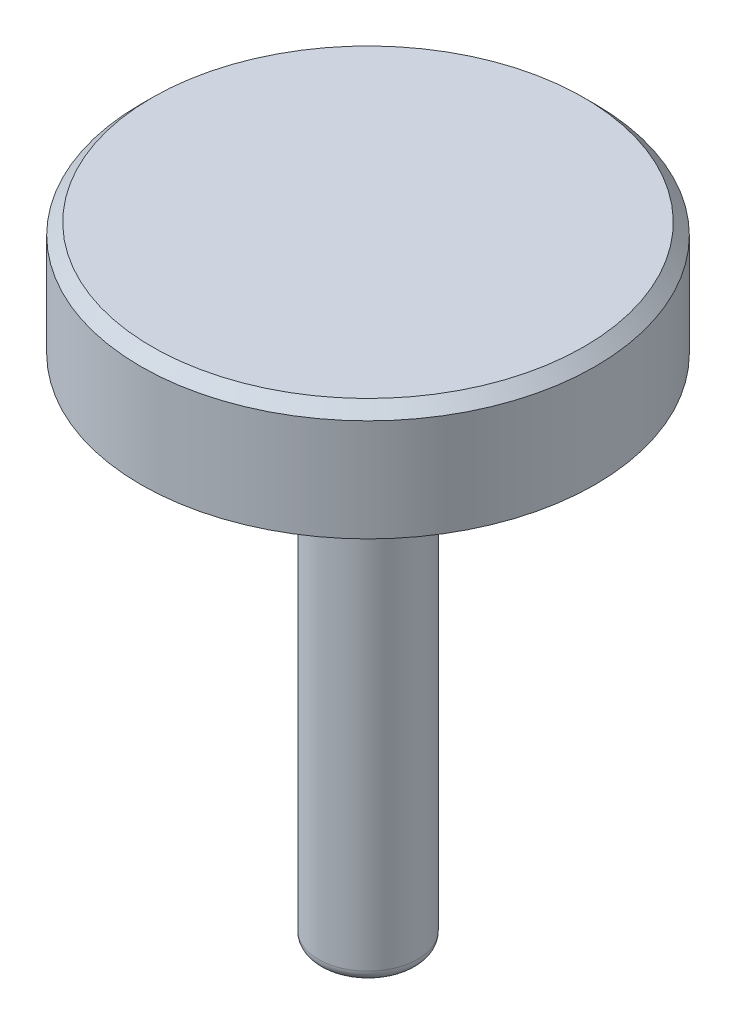
from build123d import *

# Parameters (mm, degrees)
FILLET1_R     = 0.2
CHAMFER1_SIZE = 0.2


with BuildPart() as part:
    # Sketch2 → Revolve1 (revolve)
    with BuildSketch(Plane.XY):
        Polygon((0, 0), (0.875, 0), (0.875, 9), (4, 9), (4, 11), (0, 11), align=None)
    revolve(axis=Axis((0, 11, 0), (0, -1, 0)))

    # Fillet1
    fillet1_edges = [part.edges().sort_by_distance(p)[0] for p in [
        (-0.875, 9, 0),
        (-0.875, 0, 0),
    ]]
    fillet(fillet1_edges, radius=FILLET1_R)

    # Chamfer1
    chamfer1_edges = [part.edges().sort_by_distance(p)[0] for p in [
        (-4, 11, 0),
    ]]
    chamfer(chamfer1_edges, length=CHAMFER1_SIZE)


solid = part.part
